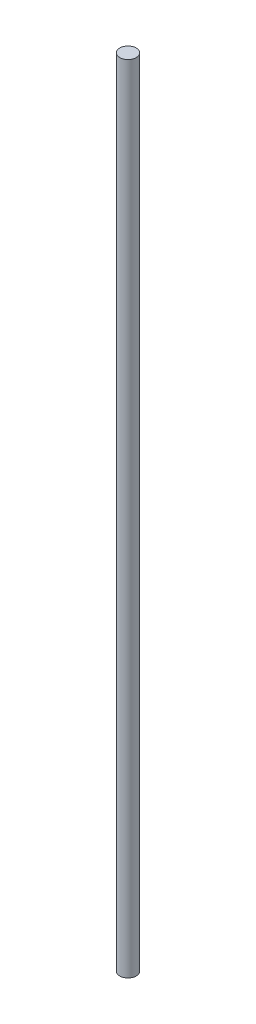
from build123d import *

# Parameters (mm, degrees)
SKETCH1_R           = 19.05
BOSS_EXTRUDE1_DEPTH = 1828.8


with BuildPart() as part:
    # Sketch1 → Boss-Extrude1 (new body)
    with BuildSketch(Plane(origin=(0, 0, 0), x_dir=(1, 0, 0), z_dir=(0, 1, 0))):
        Circle(SKETCH1_R)
    extrude(amount=BOSS_EXTRUDE1_DEPTH)


solid = part.part
